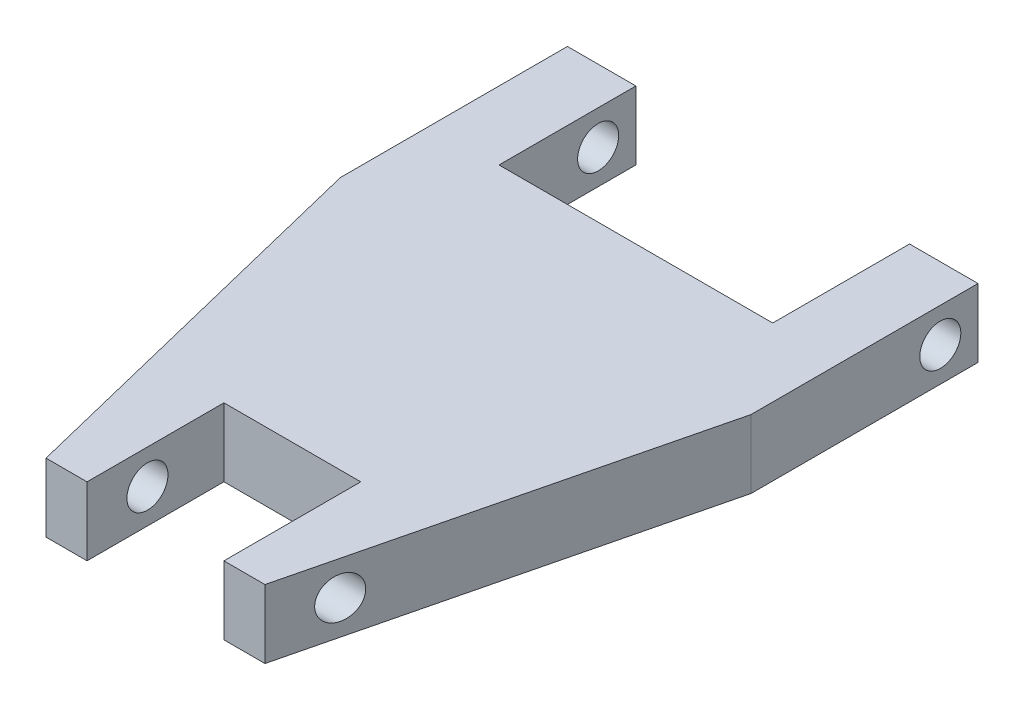
from build123d import *

# Parameters (mm, degrees)
BOSS_EXTRUDE1_DEPTH     = 3.175
SKETCH2_R               = 1.905
CUT_EXTRUDE1_DEPTH      = 20.05
CUT_EXTRUDE1_DEPTH_BACK = 20.05


with BuildPart() as part:
    # Sketch1 → Boss-Extrude1 (new body, symmetric)
    with BuildSketch(Plane(origin=(0, 0, 0), x_dir=(1, 0, 0), z_dir=(0, 1, 0))):
        Polygon((-19.05, 28.623002286), (-19.05, 7.559996871), (-10.16, -28.655798535), (-6.35, -28.655798535), (-6.35, -15.955798535), (6.35, -15.955798535), (6.35, -28.655798535), (10.16, -28.655798535), (19.05, 7.559996871), (19.05, 28.623002286), (12.7, 28.623002286), (12.7, 15.923002286), (-12.7, 15.923002286), (-12.7, 28.623002286), align=None)
    extrude(amount=BOSS_EXTRUDE1_DEPTH, both=True)

    # Sketch2 → Cut-Extrude1 (cut, two sides)
    with BuildSketch(Plane.ZY) as cut_extrude1_sk:
        with Locations((-25.12220376, 0)):
            Circle(SKETCH2_R)
        with Locations((23.04976617, 0)):
            Circle(SKETCH2_R)
    extrude(amount=CUT_EXTRUDE1_DEPTH, mode=Mode.SUBTRACT)
    extrude(cut_extrude1_sk.sketch, amount=-CUT_EXTRUDE1_DEPTH_BACK, mode=Mode.SUBTRACT)


solid = part.part
